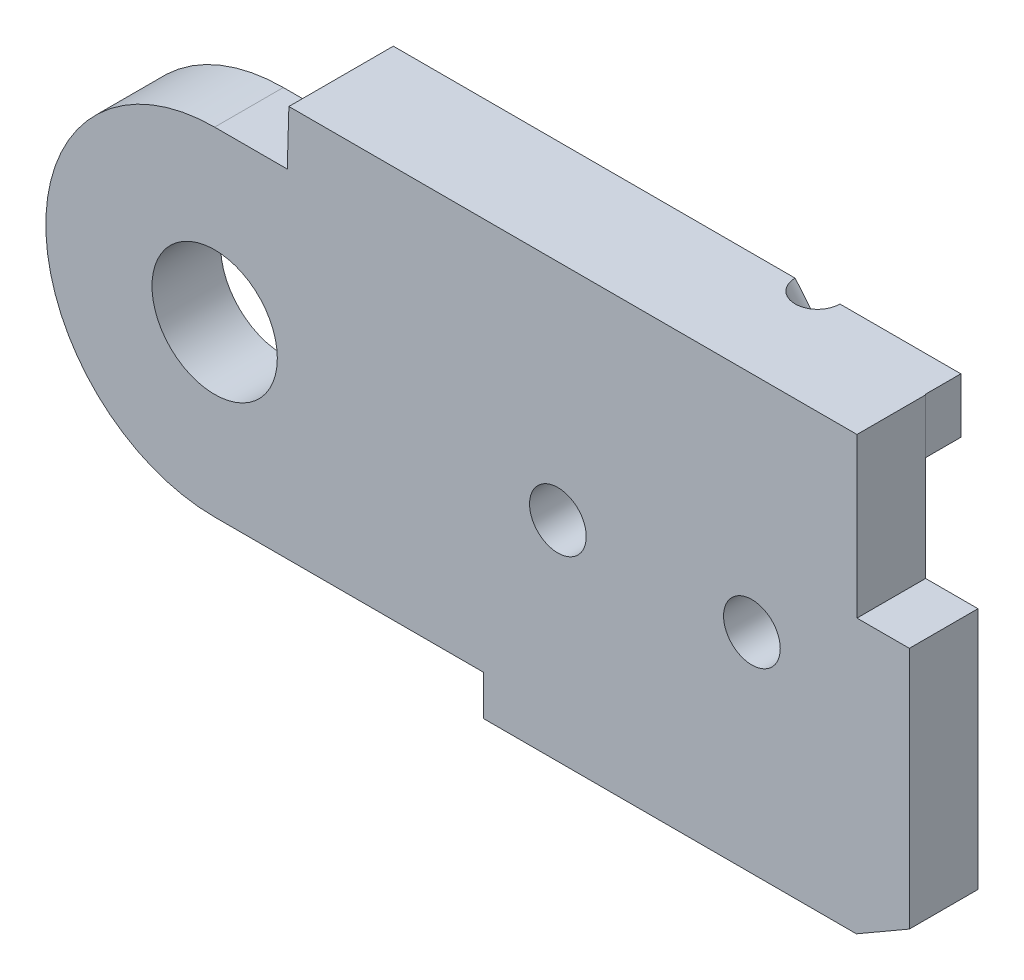
from build123d import *

# Parameters (mm, degrees)
BOSS_EXTRUDE1_DEPTH  = 2
BOSS_EXTRUDE6_DEPTH  = 2.5
CUT_EXTRUDE6_DEPTH   = 2.5
BOSS_EXTRUDE14_DEPTH = 2.3
SKETCH32_R           = 2.1
CUT_EXTRUDE7_DEPTH   = 2.3
SKETCH33_W           = 12.5
SKETCH33_H           = 1.343145751
BOSS_EXTRUDE15_DEPTH = 1.2
SKETCH35_W           = 5.479645997
SKETCH35_H           = 5.327993755
CUT_EXTRUDE8_DEPTH   = 2.4
SKETCH36_W           = 3.7
SKETCH36_H           = 1.827993755
CUT_EXTRUDE9_DEPTH   = 2.4
SKETCH37_R           = 3.9
BOSS_EXTRUDE16_DEPTH = 2.3
CUT_EXTRUDE10_DEPTH  = 5.3
SKETCH43_R           = 2.5
BOSS_EXTRUDE17_DEPTH = 1.2
SKETCH44_R           = 0.95
CUT_EXTRUDE11_DEPTH  = 9
SKETCH45_R           = 2
CUT_EXTRUDE12_DEPTH  = 2.5
SKETCH52_R           = 0.75
CUT_EXTRUDE13_DEPTH  = 10


with BuildPart() as part:
    # Sketch3 → Boss-Extrude1 (new body)
    with BuildSketch(Plane.XY):
        with BuildLine():
            Line((8, 0), (9, -2.5))
            Line((9, -2.5), (9, -7))
            Line((9, -7), (21.5, -7))
            Line((21.5, -7), (25.050252532, -4.949747468))
            ThreePointArc((25.050252532, -4.949747468), (36.467156728, -2.678784027), (30, 7))
            Line((30, 7), (27, 7.5))
            Line((27, 7.5), (5.656854249, 7.5))
            Line((5.656854249, 7.5), (5.656854249, 5.656854249))
            ThreePointArc((5.656854249, 5.656854249), (7.39103626, 3.061467459), (8, 0))
        make_face()
    extrude(amount=BOSS_EXTRUDE1_DEPTH)

    # Sketch22 → Boss-Extrude6 (add)
    with BuildSketch(Plane.XY.offset(2)):
        with BuildLine():
            Line((5.656854249, 5.656854249), (2.486790148, 5.656854249))
            Line((2.486790148, 5.656854249), (2.486790148, 7.5))
            Line((2.486790148, 7.5), (5.656854249, 7.5))
            Line((5.656854249, 7.5), (21.5, 7.5))
            Line((21.5, 7.5), (27, 7.5))
            Line((27, 7.5), (27, 2.172006245))
            Line((27, 2.172006245), (23.275126266, 2.172006245))
            Line((23.275126266, 2.172006245), (23.275126266, -5.974873734))
            Line((23.275126266, -5.974873734), (21.5, -7))
            Line((21.5, -7), (9, -7))
            Line((9, -7), (9, -2.5))
            Line((9, -2.5), (8, 0))
            ThreePointArc((8, 0), (7.39103626, 3.061467459), (5.656854249, 5.656854249))
        make_face()
    extrude(amount=BOSS_EXTRUDE6_DEPTH)

    # Sketch26 → Cut-Extrude6 (cut)
    with BuildSketch(Plane.XY.offset(2)):
        Polygon((18.098080448, 5.3), (2.530052458, 5.3), (2.530052458, 4), (18.098080448, 4), (27, 4), (27, 5.3), align=None)
    extrude(amount=CUT_EXTRUDE6_DEPTH, mode=Mode.SUBTRACT)


with BuildPart() as body_2:
    # Sketch31 → Boss-Extrude14 (new body)
    with BuildSketch(Plane.XY.offset(4.5)):
        with BuildLine():
            Line((2.432688066, 5.656854249), (0, 5.656854249))
            ThreePointArc((0, 5.656854249), (-5.656854249, 0), (0, -5.656854249))
            Line((0, -5.656854249), (9, -5.656854249))
            Line((9, -5.656854249), (9, -7))
            Line((9, -7), (21.5, -7))
            Line((21.5, -7), (23.275126266, -5.974873734))
            Line((23.275126266, -5.974873734), (23.275126266, 2.172006245))
            Line((23.275126266, 2.172006245), (27, 2.172006245))
            Line((27, 2.172006245), (27, 7.5))
            Line((27, 7.5), (2.486790148, 7.5))
            Line((2.486790148, 7.5), (2.432688066, 5.656854249))
        make_face()
    extrude(amount=BOSS_EXTRUDE14_DEPTH)

    # Sketch32 → Cut-Extrude7 (cut)
    with BuildSketch(Plane.XY.offset(6.8)):
        Circle(SKETCH32_R)
    extrude(amount=-CUT_EXTRUDE7_DEPTH, mode=Mode.SUBTRACT)

    # Sketch33 → Boss-Extrude15 (add)
    with BuildSketch(Plane.XY.offset(6.8)):
        with Locations((15.25, -6.328427125)):
            Rectangle(SKETCH33_W, SKETCH33_H)
        Polygon((2.486790148, 7.5), (21.5, 7.5), (21.5, 5.656854249), (2.432688066, 5.656854249), align=None)
    extrude(amount=BOSS_EXTRUDE15_DEPTH)


with BuildPart() as cut_extrude8_tool:
    # Sketch35 → Cut-Extrude8 (new body)
    with BuildSketch(Plane.XY.offset(6.8)):
        with Locations((24.260177002, 4.836003123)):
            Rectangle(SKETCH35_W, SKETCH35_H)
    extrude(amount=-CUT_EXTRUDE8_DEPTH)


with BuildPart() as part_1:
    add(part.part)

    # Cut-Extrude8: cut by cut_extrude8_tool
    add(cut_extrude8_tool.part, mode=Mode.SUBTRACT)

    # Sketch36 → Cut-Extrude9 (cut)
    with BuildSketch(Plane.XY.offset(4.4)):
        with Locations((25.15, 3.086003123)):
            Rectangle(SKETCH36_W, SKETCH36_H)
    extrude(amount=-CUT_EXTRUDE9_DEPTH, mode=Mode.SUBTRACT)

    # Sketch37 → Boss-Extrude16 (add)
    with BuildSketch(Plane.XY.offset(2)):
        with Locations((30, 0)):
            Circle(SKETCH37_R)
    extrude(amount=BOSS_EXTRUDE16_DEPTH)

    # Sketch39 → Cut-Extrude10 (cut, through all)
    with BuildSketch(Plane.XY.offset(4.3)):
        with BuildLine():
            Line((29, 1.732050808), (29, -1.732050808))
            ThreePointArc((29, -1.732050808), (32, 0), (29, 1.732050808))
        make_face()
    extrude(amount=-CUT_EXTRUDE10_DEPTH, mode=Mode.SUBTRACT)


with BuildPart() as body_2_1:
    add(body_2.part)

    # Cut-Extrude8: cut by cut_extrude8_tool
    add(cut_extrude8_tool.part, mode=Mode.SUBTRACT)

    # Sketch43 → Boss-Extrude17 (add)
    with BuildSketch(Plane.XY.offset(6.8)):
        with Locations((11.5, 0)):
            Circle(SKETCH43_R)
        with Locations((18, 0)):
            Circle(SKETCH43_R)
    extrude(amount=BOSS_EXTRUDE17_DEPTH)


with BuildPart() as cut_extrude11_tool:
    # Sketch44 → Cut-Extrude11 (new body, through all)
    with BuildSketch(Plane.XY.offset(8)):
        with Locations((11.5, 0)):
            Circle(SKETCH44_R)
        with Locations((18, 0)):
            Circle(SKETCH44_R)
    extrude(amount=-CUT_EXTRUDE11_DEPTH)


with BuildPart() as part_2:
    add(part_1.part)

    # Cut-Extrude11: cut by cut_extrude11_tool
    add(cut_extrude11_tool.part, mode=Mode.SUBTRACT)

    # Sketch45 → Cut-Extrude12 (cut)
    with BuildSketch(Plane(origin=(0, 0, 0), x_dir=(-1, 0, 0), z_dir=(0, 0, -1))):
        with Locations((-11.5, 0)):
            Circle(SKETCH45_R)
        with Locations((-18, 0)):
            Circle(SKETCH45_R)
    extrude(amount=-CUT_EXTRUDE12_DEPTH, mode=Mode.SUBTRACT)


with BuildPart() as body_2_2:
    add(body_2_1.part)

    # Cut-Extrude11: cut by cut_extrude11_tool
    add(cut_extrude11_tool.part, mode=Mode.SUBTRACT)

    # Sketch52 → Cut-Extrude13 (cut, along a direction that is not the sketch's normal)
    with BuildSketch(Plane.XZ.offset(-5.656854249)):
        with Locations((18.235476819, 8)):
            Circle(SKETCH52_R)
    extrude(amount=-CUT_EXTRUDE13_DEPTH, dir=(0.640410196, -0.76803306, 0), mode=Mode.SUBTRACT)


with BuildPart() as body_3:
    # Mirror1: mirrored copy
    add(body_2_2.part.mirror(Plane.XY.offset(8)))


with BuildPart() as body_4:
    # Mirror1 2: mirrored copy
    add(part_2.part.mirror(Plane.XY.offset(8)))


solid = body_3.part
